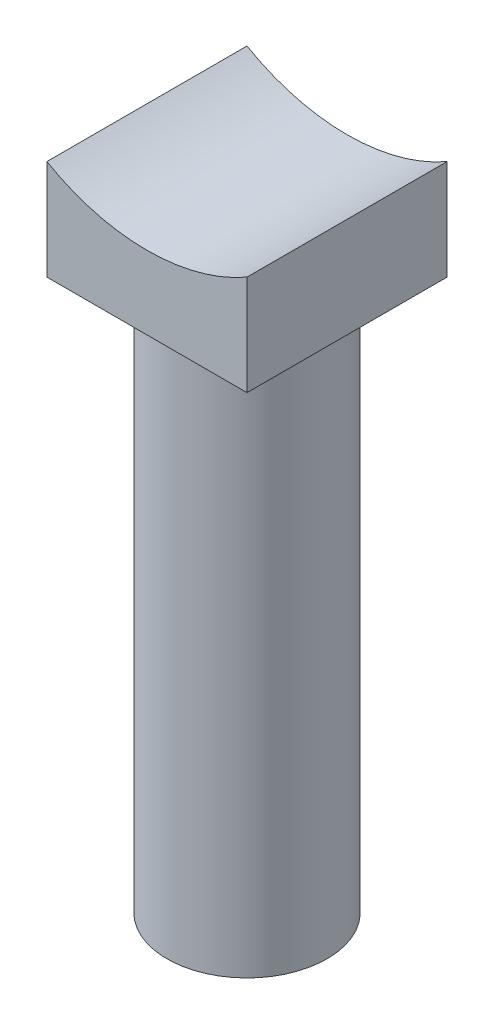
from build123d import *

# Parameters (mm, degrees)
BOSS_EXTRUDE1_DEPTH = 20
SKETCH2_R           = 8
BOSS_EXTRUDE2_DEPTH = 55


with BuildPart() as part:
    # Sketch1 → Boss-Extrude1 (new body)
    with BuildSketch(Plane.XY):
        with BuildLine():
            Line((0, 10), (0, 0))
            Line((0, 0), (20, 0))
            Line((20, 0), (20, 10))
            ThreePointArc((20, 10), (10, 7.320508076), (0, 10))
        make_face()
    extrude(amount=BOSS_EXTRUDE1_DEPTH)

    # Sketch2 → Boss-Extrude2 (add)
    with BuildSketch(Plane.XZ):
        with Locations((10, 10)):
            Circle(SKETCH2_R)
    extrude(amount=BOSS_EXTRUDE2_DEPTH)


solid = part.part
